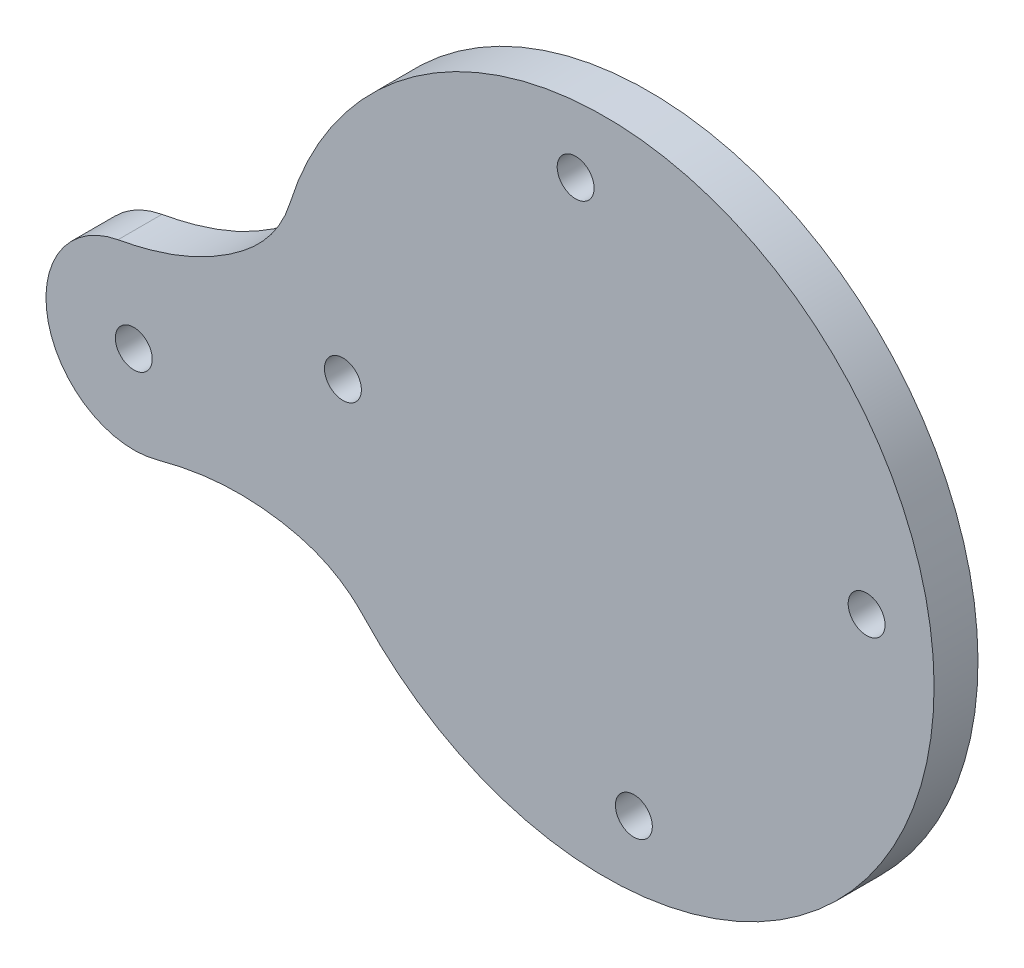
from build123d import *

# Parameters (mm, degrees)
ESQUISSE1_R                               = 37.5
BOSS_EXTRU_1_DEPTH                        = 5
TROU_POUR_TARAUDAGE_POUR_TROU_TARAUD_M5_D = 4.2
R_P_TITION_CIRCULAIRE1_COUNT              = 4
BOSS_EXTRU_2_DEPTH                        = 5
TROU_POUR_TARAUDAGE_POUR_TROU_TARAUD_2_D  = 4.2


with BuildPart() as part:
    # Esquisse1 → Boss.-Extru.1 (new body)
    with BuildSketch(Plane.XY):
        Circle(ESQUISSE1_R)
    extrude(amount=BOSS_EXTRU_1_DEPTH)

    # Trou pour taraudage pour trou taraud_ M5 (through all)
    with Locations(Plane.XY.offset(5)):
        with Locations((3.3162691, -29.816142595)):
            trou_pour_taraudage_pour_trou_taraud_m5 = Hole(TROU_POUR_TARAUDAGE_POUR_TROU_TARAUD_M5_D / 2)

    # Répétition circulaire1: Trou pour taraudage pour trou taraud_ M5 ×4 about axis
    r_p_tition_circulaire1_axis = Axis((0, 0, 0), (0, 0, 1))
    for i in range(1, R_P_TITION_CIRCULAIRE1_COUNT):
        add(trou_pour_taraudage_pour_trou_taraud_m5.rotate(r_p_tition_circulaire1_axis, i * 360 / R_P_TITION_CIRCULAIRE1_COUNT), mode=Mode.SUBTRACT)

    # Esquisse4 → Boss.-Extru.2 (add)
    with BuildSketch(Plane.XY.offset(5)):
        with BuildLine():
            ThreePointArc((-55.427721141, -2.370238342), (-63.3788401, -14.426455821), (-50.992891265, -21.853497228))
            add(Edge.make_bspline(
                [(-27.47890369, -25.517833999), (-30.318179528, -22.460357126), (-38.333660049, -19.857417418), (-46.174070418, -20.537027691), (-50.992891265, -21.853497228)],
                knots=[0, 0, 0, 0, 0.450210397, 1, 1, 1, 1], degree=3))
            ThreePointArc((-27.47890369, -25.517833999), (-36.564715442, -8.322955281), (-35.816319782, 11.110411212))
            add(Edge.make_bspline(
                [(-35.816319782, 11.110411212), (-37.052534505, 7.125260617), (-43.151729094, 1.309501984), (-50.513854322, -1.471328291), (-55.427721141, -2.370238342)],
                knots=[0, 0, 0, 0, 0.450210397, 1, 1, 1, 1], degree=3))
        make_face()
    extrude(amount=-BOSS_EXTRU_2_DEPTH)

    # Trou pour taraudage pour trou taraud 2 (through all)
    with Locations(Plane.XY.offset(5)):
        with Locations((-53.628249316, -12.207001079)):
            Hole(TROU_POUR_TARAUDAGE_POUR_TROU_TARAUD_2_D / 2)


solid = part.part
